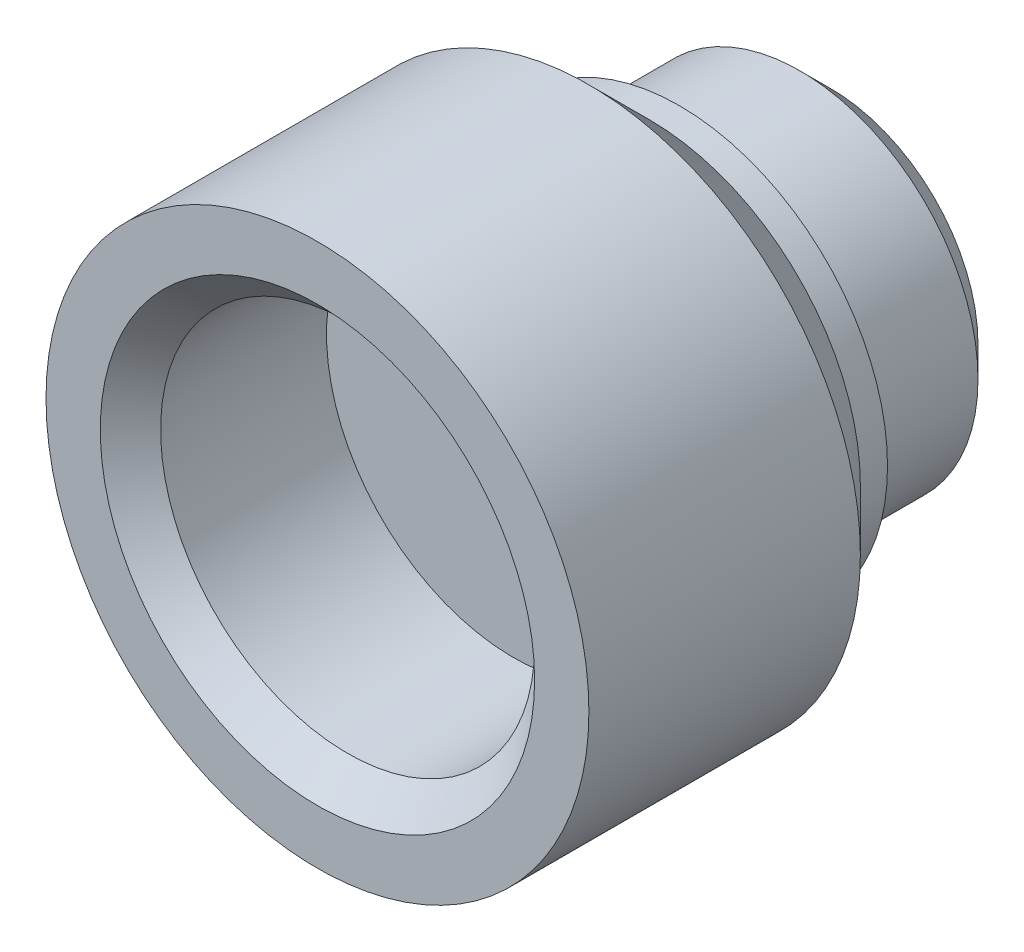
from build123d import *

# Parameters (mm, degrees)
SKETCH1_R           = 2.95
SKETCH1_R_2         = 1
BOSS_EXTRUDE1_DEPTH = 3
SKETCH2_R           = 4.5
SKETCH2_R_2         = 1
BOSS_EXTRUDE2_DEPTH = 5.5
SKETCH3_R           = 3.1
CUT_EXTRUDE1_DEPTH  = 3.25
CHAMFER1_SIZE       = 0.5
CHAMFER2_SIZE       = 0.5
SKETCH4_R           = 3.45
SKETCH4_R_2         = 1
BOSS_EXTRUDE3_DEPTH = 0.5
CHAMFER3_SIZE       = 1


with BuildPart() as part:
    # Sketch1 → Boss-Extrude1 (new body)
    with BuildSketch(Plane.XY):
        Circle(SKETCH1_R)
        Circle(SKETCH1_R_2, mode=Mode.SUBTRACT)
    extrude(amount=BOSS_EXTRUDE1_DEPTH)

    # Sketch2 → Boss-Extrude2 (add)
    with BuildSketch(Plane.XY.offset(3)):
        Circle(SKETCH2_R)
        Circle(SKETCH2_R_2, mode=Mode.SUBTRACT)
    extrude(amount=BOSS_EXTRUDE2_DEPTH)

    # Sketch3 → Cut-Extrude1 (cut)
    with BuildSketch(Plane.XY.offset(8.5)):
        Circle(SKETCH3_R)
    extrude(amount=-CUT_EXTRUDE1_DEPTH, mode=Mode.SUBTRACT)

    # Chamfer1
    chamfer1_edges = [part.edges().sort_by_distance(p)[0] for p in [
        (-3.1, 0, 8.5),
    ]]
    chamfer(chamfer1_edges, length=CHAMFER1_SIZE)

    # Chamfer2
    chamfer2_edges = [part.edges().sort_by_distance(p)[0] for p in [
        (-2.95, 0, 0),
    ]]
    chamfer(chamfer2_edges, length=CHAMFER2_SIZE)

    # Sketch4 → Boss-Extrude3 (add)
    with BuildSketch(Plane(origin=(0, 0, 3), x_dir=(-1, 0, 0), z_dir=(0, 0, -1))):
        Circle(SKETCH4_R)
        Circle(SKETCH4_R_2, mode=Mode.SUBTRACT)
    extrude(amount=BOSS_EXTRUDE3_DEPTH)

    # Chamfer3
    chamfer3_edges = [part.edges().sort_by_distance(p)[0] for p in [
        (-4.5, 0, 3),
    ]]
    chamfer(chamfer3_edges, length=CHAMFER3_SIZE)


solid = part.part
